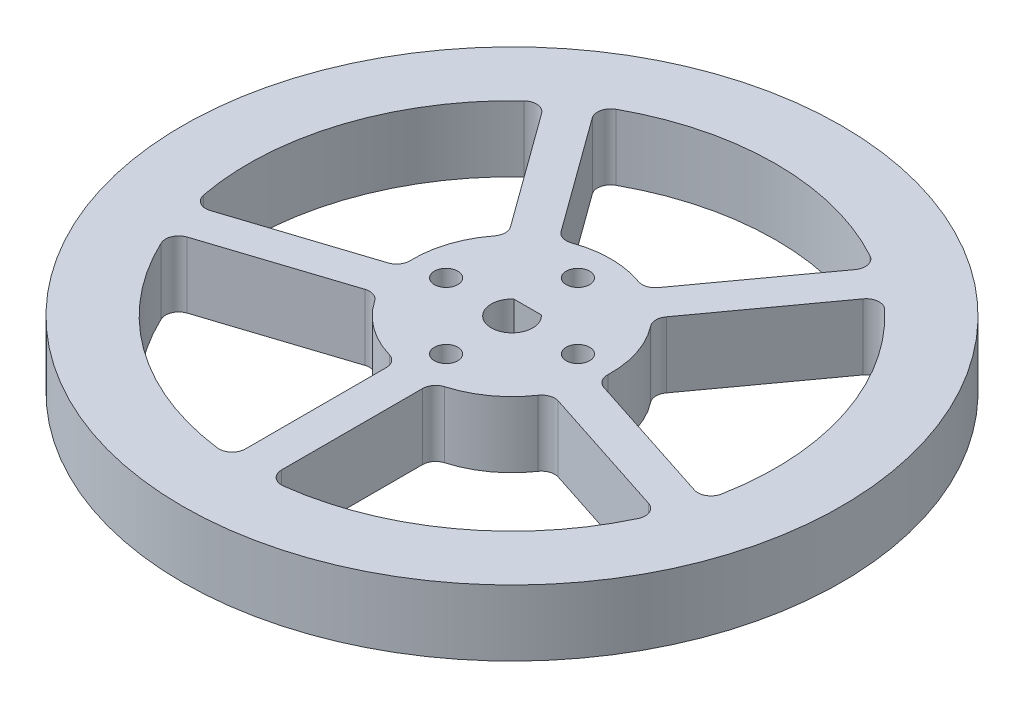
from build123d import *

# Parameters (mm, degrees)
SKETCH1_R           = 31.75
SKETCH1_R_2         = 1.1303
BOSS_EXTRUDE1_DEPTH = 6.35
SKETCH2_R           = 25.4
SKETCH2_R_2         = 9.525
CUT_EXTRUDE1_DEPTH  = 6.35
BOSS_EXTRUDE2_DEPTH = 6.35
CIRPATTERN1_COUNT   = 5


with BuildPart() as part:
    # Sketch1 → Boss-Extrude1 (new body)
    with BuildSketch(Plane(origin=(0, 0, 0), x_dir=(1, 0, 0), z_dir=(0, 1, 0))):
        Circle(SKETCH1_R)
        with Locations((-6.35, 0)):
            Circle(SKETCH1_R_2, mode=Mode.SUBTRACT)
        with Locations((0, 6.35)):
            Circle(SKETCH1_R_2, mode=Mode.SUBTRACT)
        with Locations((6.35, 0)):
            Circle(SKETCH1_R_2, mode=Mode.SUBTRACT)
        with Locations((0, -6.35)):
            Circle(SKETCH1_R_2, mode=Mode.SUBTRACT)
        with BuildLine():
            Line((-1.322875656, 1.5), (1.322875656, 1.5))
            ThreePointArc((1.322875656, 1.5), (0, -2), (-1.322875656, 1.5))
        make_face(mode=Mode.SUBTRACT)
    extrude(amount=BOSS_EXTRUDE1_DEPTH)

    # Sketch2 → Cut-Extrude1 (cut)
    with BuildSketch(Plane(origin=(0, 6.35, 0), x_dir=(1, 0, 0), z_dir=(0, 1, 0))):
        Circle(SKETCH2_R)
        Circle(SKETCH2_R_2, mode=Mode.SUBTRACT)
    extrude(amount=-CUT_EXTRUDE1_DEPTH, mode=Mode.SUBTRACT)

    # Sketch3 → Boss-Extrude2 (add)
    with BuildSketch(Plane(origin=(0, 6.35, 0), x_dir=(1, 0, 0), z_dir=(0, 1, 0))):
        with BuildLine():
            Line((-1.74625, -10.365049973), (-1.74625, -23.940742176))
            ThreePointArc((-1.74625, -23.940742176), (-2.176223959, -24.893242176), (-3.175, -25.200781238))
            ThreePointArc((-3.175, -25.200781238), (0, -25.4), (3.175, -25.200781238))
            ThreePointArc((3.175, -25.200781238), (2.176223959, -24.893242176), (1.74625, -23.940742176))
            Line((1.74625, -23.940742176), (1.74625, -10.365049973))
            ThreePointArc((1.74625, -10.365049973), (2.000483483, -9.602738762), (2.661397059, -9.145632329))
            ThreePointArc((2.661397059, -9.145632329), (0, -9.525), (-2.661397059, -9.145632329))
            ThreePointArc((-2.661397059, -9.145632329), (-2.000483483, -9.602738762), (-1.74625, -10.365049973))
        make_face()
    boss_extrude2 = extrude(amount=-BOSS_EXTRUDE2_DEPTH)

    # CirPattern1: Boss-Extrude2 ×5 about axis
    cirpattern1_axis = Axis((0, 0, 0), (0, 1, 0))
    for i in range(1, CIRPATTERN1_COUNT):
        add(boss_extrude2.rotate(cirpattern1_axis, i * 360 / CIRPATTERN1_COUNT))


solid = part.part
